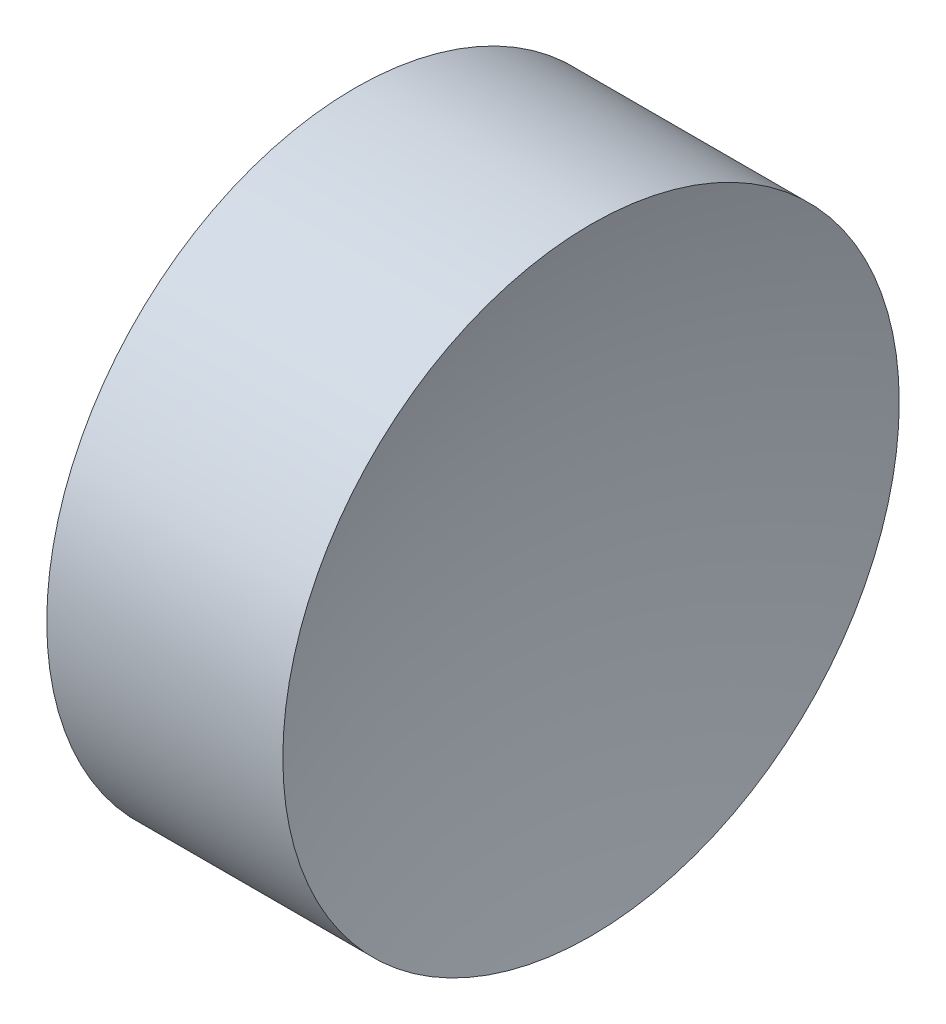
from build123d import *


with BuildPart() as part:
    # 草图1 → 旋转1 (revolve)
    with BuildSketch(Plane.XY, mode=Mode.PRIVATE) as revolve_1_sk:
        with BuildLine():
            Line((46.545221984, 26.089041149), (49.545221984, 26.089041149))
            ThreePointArc((49.545221984, 26.089041149), (49.779443812, 29.298051112), (50.477144603, 32.439041149))
            Line((50.477144603, 32.439041149), (48.045221984, 32.439041149))
            Line((48.045221984, 32.439041149), (45.613299365, 32.439041149))
            ThreePointArc((45.613299365, 32.439041149), (46.311000156, 29.298051112), (46.545221984, 26.089041149))
        make_face()
    revolve(revolve_1_sk.sketch.rotate(Axis((42.449861114, 26.089041149, 0), (1, 0, 0)), 90), axis=Axis((42.449861114, 26.089041149, 0), (1, 0, 0)))  # turned: the seam where the file's is


solid = part.part
